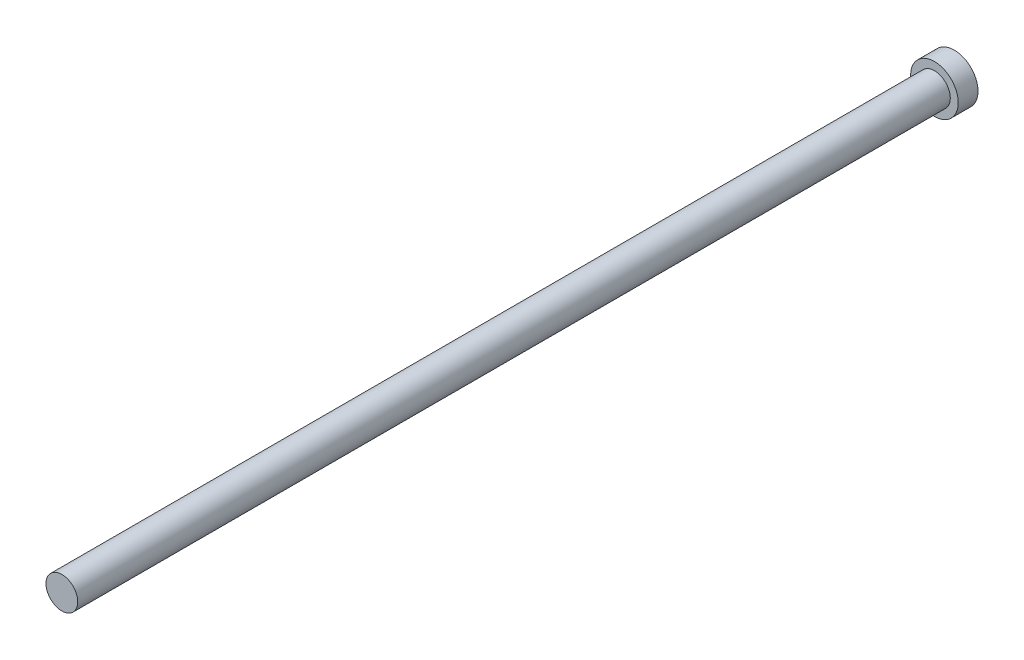
from build123d import *

# Parameters (mm, degrees)
SKETCH1_R           = 1.016
BOSS_EXTRUDE1_DEPTH = 55.88
SKETCH2_R           = 1.524
BOSS_EXTRUDE2_DEPTH = 1.27


with BuildPart() as part:
    # Sketch1 → Boss-Extrude1 (new body)
    with BuildSketch(Plane.XY):
        Circle(SKETCH1_R)
    extrude(amount=BOSS_EXTRUDE1_DEPTH)

    # Sketch2 → Boss-Extrude2 (add)
    with BuildSketch(Plane(origin=(0, 0, 0), x_dir=(-1, 0, 0), z_dir=(0, 0, -1))):
        Circle(SKETCH2_R)
    extrude(amount=BOSS_EXTRUDE2_DEPTH)


solid = part.part
